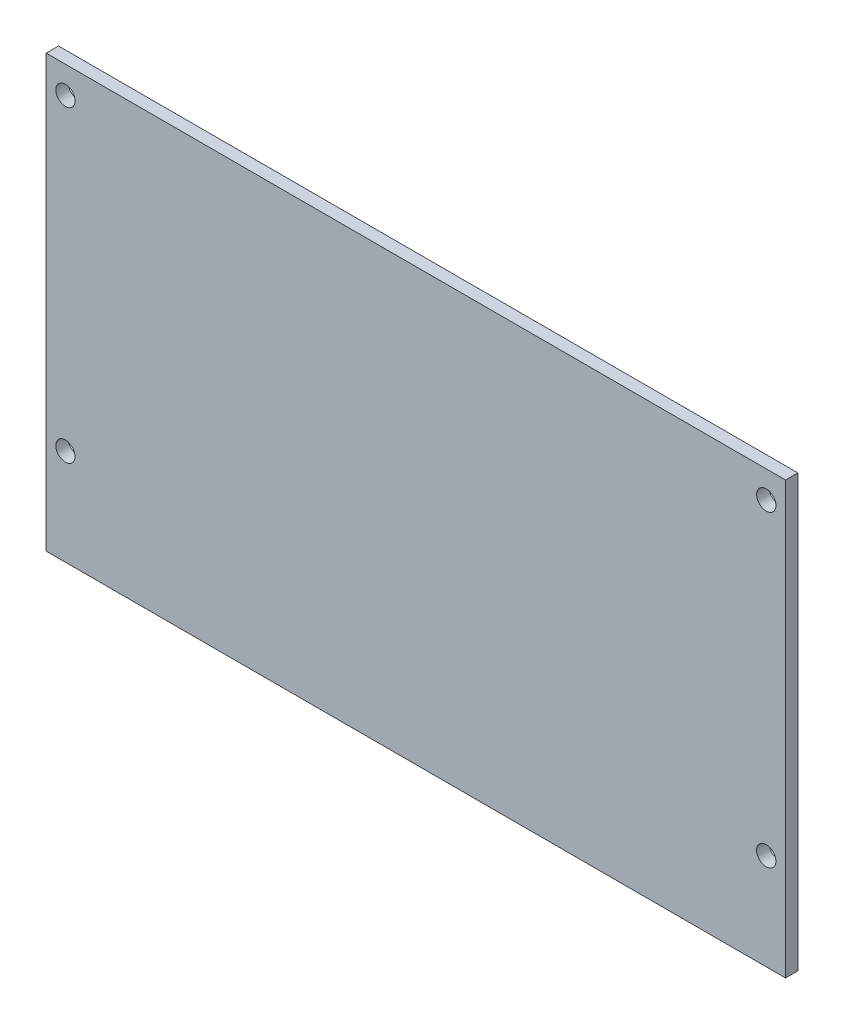
from build123d import *

# Parameters (mm, degrees)
SKETCH1_W           = 96
SKETCH1_H           = 56
SKETCH1_R           = 1.25
BOSS_EXTRUDE1_DEPTH = 1.6


with BuildPart() as part:
    # Sketch1 → Boss-Extrude1 (new body)
    with BuildSketch(Plane.XY):
        Rectangle(SKETCH1_W, SKETCH1_H)
        with Locations((-45.5, 24.5)):
            Circle(SKETCH1_R, mode=Mode.SUBTRACT)
        with Locations((-45.5, -15.5)):
            Circle(SKETCH1_R, mode=Mode.SUBTRACT)
        with Locations((45.5, -15.5)):
            Circle(SKETCH1_R, mode=Mode.SUBTRACT)
        with Locations((45.5, 24.5)):
            Circle(SKETCH1_R, mode=Mode.SUBTRACT)
    extrude(amount=BOSS_EXTRUDE1_DEPTH)


solid = part.part
